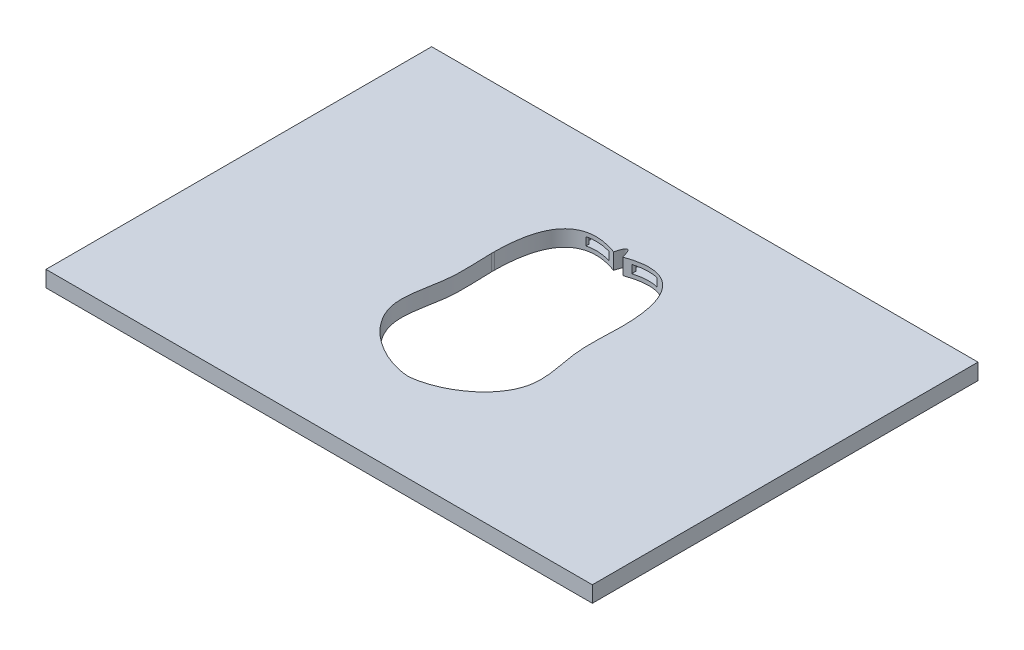
from build123d import *

# Parameters (mm, degrees)
SKETCH_2_W             = 34
SKETCH_2_H             = 24
EXTRUDE_1_DEPTH        = 1
CUT_EXTRUDE_2_DEPTH    = 1
SKETCH_4_W             = 2
SKETCH_4_H             = 0.5
CUT_EXTRUDE_3_DEPTH    = 3
SKETCH_5_W             = 1.5
SKETCH_5_H             = 0.5
CUT_EXTRUDE_4_DEPTH    = 3
SKETCH_6_W             = 0.2
SKETCH_6_H             = 0.5
CUT_EXTRUDE_6_DEPTH    = 1.2
SKETCH_7_W             = 0.2
SKETCH_7_H             = 0.5
CUT_EXTRUDE_7_DEPTH    = 1
PATTERN_LINEAR_1_COUNT = 2
PATTERN_LINEAR_1_PITCH = 2.917


with BuildPart() as part:
    # 草图2 → 凸台-拉伸1 (new body)
    with BuildSketch(Plane(origin=(0, 0, 0), x_dir=(1, 0, 0), z_dir=(0, 1, 0))):
        Rectangle(SKETCH_2_W, SKETCH_2_H)
    extrude(amount=EXTRUDE_1_DEPTH)

    # 草图3 → 切除-拉伸2 (cut)
    with BuildSketch(Plane(origin=(0, 1, 0), x_dir=(1, 0, 0), z_dir=(0, 1, 0))):
        with BuildLine():
            Line((2.852693105, 6.5), (0, 6.5))
            Line((0, 6.5), (0, -6.5))
            add(Edge.make_bspline(
                [(4, -3.960322269), (3.291830105, -5.33321398), (1.554438327, -6.399660403), (0, -6.5)],
                knots=[0.726831855, 0.726831855, 0.726831855, 0.726831855, 0.974825143, 0.974825143, 0.974825143, 0.974825143], degree=3))
            Line((4, -3.960322269), (4, 0))
            add(Edge.make_bspline(
                [(4, 2.711962076), (3.993732983, 1.774234816), (3.903899915, 0.904091061), (4, 0)],
                knots=[0.362705738, 0.362705738, 0.362705738, 0.362705738, 0.509475385, 0.509475385, 0.509475385, 0.509475385], degree=3))
            Line((4, 2.711962076), (4, 2.909239089))
            add(Edge.make_bspline(
                [(2.852693105, 6.5), (3.766558676, 5.806047297), (3.99030544, 4.279578326), (4, 2.909239089)],
                knots=[0.140232201, 0.140232201, 0.140232201, 0.140232201, 0.352466659, 0.352466659, 0.352466659, 0.352466659], degree=3))
        make_face()
        with BuildLine():
            Line((0, -6.5), (0, 6.5))
            Line((0, 6.5), (-2.852693105, 6.5))
            add(Edge.make_bspline(
                [(-2.852693105, 6.5), (-3.766558676, 5.806047297), (-3.99030544, 4.279578326), (-4, 2.909239089)],
                knots=[0.140232201, 0.140232201, 0.140232201, 0.140232201, 0.352466659, 0.352466659, 0.352466659, 0.352466659], degree=3))
            Line((-4, 2.909239089), (-4, 2.711962076))
            add(Edge.make_bspline(
                [(-4, 2.711962076), (-3.993732983, 1.774234816), (-3.903899915, 0.904091061), (-4, 0)],
                knots=[0.362705738, 0.362705738, 0.362705738, 0.362705738, 0.509475385, 0.509475385, 0.509475385, 0.509475385], degree=3))
            Line((-4, 0), (-4, -3.960322269))
            add(Edge.make_bspline(
                [(-4, -3.960322269), (-3.291830105, -5.33321398), (-1.554438327, -6.399660403), (0, -6.5)],
                knots=[0.726831855, 0.726831855, 0.726831855, 0.726831855, 0.974825143, 0.974825143, 0.974825143, 0.974825143], degree=3))
        make_face()
        with BuildLine():
            add(Edge.make_bspline(
                [(0, 6.5), (0.096578276, 6.539787769), (0.190890779, 6.57622482), (0.282988495, 6.609417035)],
                knots=[0, 0, 0, 0, 0.010078853, 0.010078853, 0.010078853, 0.010078853], degree=3))
            Line((0, 6.5), (2.852693105, 6.5))
            add(Edge.make_bspline(
                [(0.282988495, 6.609417035), (1.47229303, 7.038044945), (2.292262606, 6.925568347), (2.852693105, 6.5)],
                knots=[0.010078853, 0.010078853, 0.010078853, 0.010078853, 0.140232201, 0.140232201, 0.140232201, 0.140232201], degree=3))
        make_face()
        with BuildLine():
            Line((-2.852693105, 6.5), (0, 6.5))
            add(Edge.make_bspline(
                [(0, 6.5), (-0.094670577, 6.539001846), (-0.187164009, 6.574784039), (-0.277528318, 6.60744631)],
                knots=[0, 0, 0, 0, 0.009879767, 0.009879767, 0.009879767, 0.009879767], degree=3))
            add(Edge.make_bspline(
                [(-0.277528318, 6.60744631), (-1.469783924, 7.038388308), (-2.291405355, 6.926219308), (-2.852693105, 6.5)],
                knots=[0.009879767, 0.009879767, 0.009879767, 0.009879767, 0.140232201, 0.140232201, 0.140232201, 0.140232201], degree=3))
        make_face()
        with BuildLine():
            add(Edge.make_bspline(
                [(0, 6.5), (-0.094670577, 6.539001846), (-0.187164009, 6.574784039), (-0.277528318, 6.60744631)],
                knots=[0, 0, 0, 0, 0.009879767, 0.009879767, 0.009879767, 0.009879767], degree=3))
            add(Edge.make_bspline(
                [(0, 6.5), (0.096578276, 6.539787769), (0.190890779, 6.57622482), (0.282988495, 6.609417035)],
                knots=[0, 0, 0, 0, 0.010078853, 0.010078853, 0.010078853, 0.010078853], degree=3))
            add(Edge.make_bspline(
                [(0.282988495, 6.609417035), (-0.002451987, 7.75268333), (-0.277528318, 6.60744631)],
                knots=[0, 0, 0, 1, 1, 1], degree=2))
        make_face()
        with BuildLine():
            add(Edge.make_bspline(
                [(-4, 0), (-4.115462181, -1.086245927), (-4.588613513, -2.485549912), (-4.117125058, -3.733258083), (-4, -3.960322269)],
                knots=[0.509475385, 0.509475385, 0.509475385, 0.509475385, 0.685815952, 0.726831855, 0.726831855, 0.726831855, 0.726831855], degree=3))
            Line((-4, -3.960322269), (-4, 0))
        make_face()
        with BuildLine():
            Line((4, 0), (4, -3.960322269))
            add(Edge.make_bspline(
                [(4, 0), (4.115462181, -1.086245927), (4.588613513, -2.485549912), (4.117125058, -3.733258083), (4, -3.960322269)],
                knots=[0.509475385, 0.509475385, 0.509475385, 0.509475385, 0.685815952, 0.726831855, 0.726831855, 0.726831855, 0.726831855], degree=3))
        make_face()
    extrude(amount=-CUT_EXTRUDE_2_DEPTH, mode=Mode.SUBTRACT)

    # 草图4 → 切除-拉伸3 (cut)
    with BuildSketch(Plane.XY.offset(8)):
        with Locations((0, 0.5)):
            Rectangle(SKETCH_4_W, SKETCH_4_H)
    extrude(amount=-CUT_EXTRUDE_3_DEPTH, mode=Mode.SUBTRACT)

    # 草图5 → 切除-拉伸4 (cut)
    with BuildSketch(Plane(origin=(0, 0, -8), x_dir=(-1, 0, 0), z_dir=(0, 0, -1))):
        with Locations((1.458123879, 0.5)):
            Rectangle(SKETCH_5_W, SKETCH_5_H)
        with Locations((-1.458123879, 0.5)):
            Rectangle(SKETCH_5_W, SKETCH_5_H)
    extrude(amount=-CUT_EXTRUDE_4_DEPTH, mode=Mode.SUBTRACT)

    # 草图6 → 切除-拉伸6 (cut)
    with BuildSketch(Plane(origin=(0, 0, 8), x_dir=(-1, 0, 0), z_dir=(0, 0, -1))):
        with Locations((1.1, 0.5)):
            Rectangle(SKETCH_6_W, SKETCH_6_H)
        Polygon((1, 0.75), (-1, 0.25), (1, 0.25), align=None)
        Polygon((1, 0.75), (-1, 0.25), (-1, 0.75), align=None)
        with Locations((-1.1, 0.5)):
            Rectangle(SKETCH_6_W, SKETCH_6_H)
    extrude(amount=CUT_EXTRUDE_6_DEPTH, mode=Mode.SUBTRACT)

    # 草图7 → 切除-拉伸7 (cut)
    with BuildSketch(Plane.XY.offset(-8)):
        Polygon((-0.708123879, 0.25), (-2.208123879, 0.75), (-2.208123879, 0.25), align=None)
        with Locations((-2.308123879, 0.5)):
            Rectangle(SKETCH_7_W, SKETCH_7_H)
        Polygon((-0.708123879, 0.25), (-2.208123879, 0.75), (-0.708123879, 0.75), align=None)
        with Locations((-0.608123879, 0.5)):
            Rectangle(SKETCH_7_W, SKETCH_7_H)
    cut_extrude_7 = extrude(amount=CUT_EXTRUDE_7_DEPTH, mode=Mode.SUBTRACT)

    # 阵列(线性)1: 切除-拉伸7 ×2
    with Locations(*[(i * PATTERN_LINEAR_1_PITCH, 0, 0) for i in range(1, PATTERN_LINEAR_1_COUNT)]):
        add(cut_extrude_7, mode=Mode.SUBTRACT)


solid = part.part
